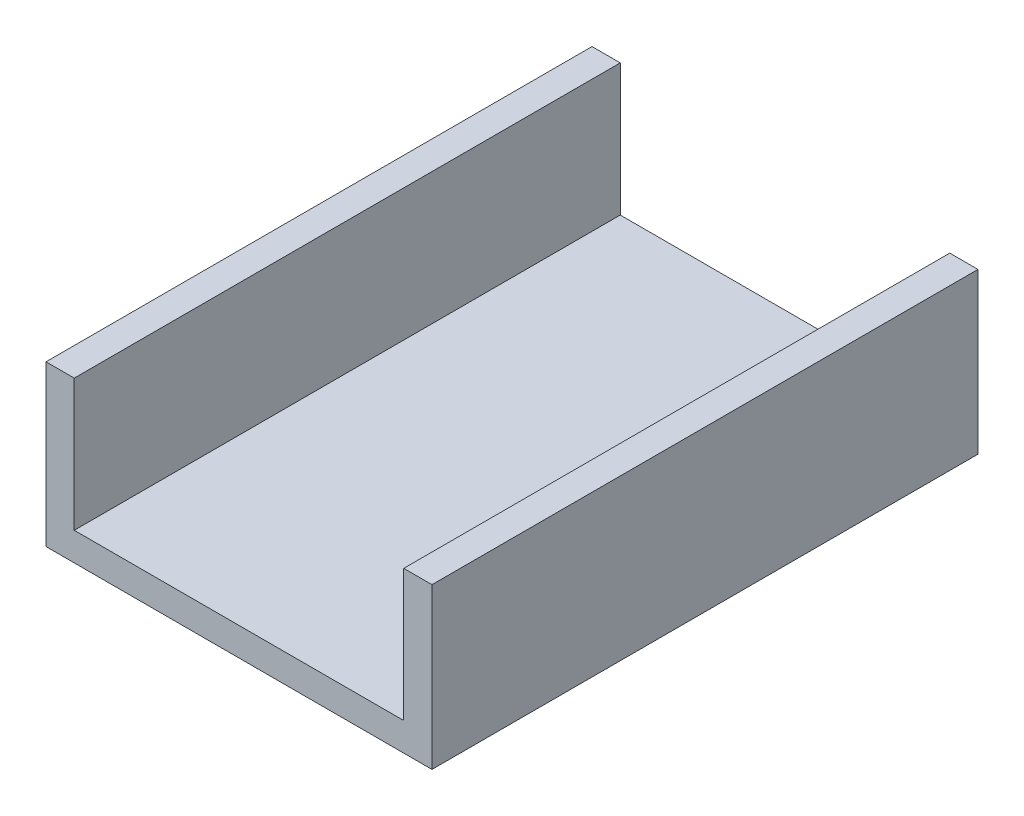
from build123d import *

# Parameters (mm, degrees)
ESQUISSE1_W        = 30
ESQUISSE1_H        = 140
ESQUISSE1_H_2      = 30
ESQUISSE1_W_2      = 350
BOSS_EXTRU_1_DEPTH = 580


with BuildPart() as part:
    # Esquisse1 → Boss.-Extru.1 (new body)
    with BuildSketch(Plane.XY):
        with Locations((-15, 100)):
            Rectangle(ESQUISSE1_W, ESQUISSE1_H)
        with Locations((-15, 15)):
            Rectangle(ESQUISSE1_W, ESQUISSE1_H_2)
        with Locations((175, 15)):
            Rectangle(ESQUISSE1_W_2, ESQUISSE1_H_2)
        with Locations((365, 15)):
            Rectangle(ESQUISSE1_W, ESQUISSE1_H_2)
        with Locations((365, 100)):
            Rectangle(ESQUISSE1_W, ESQUISSE1_H)
        Polygon((-30, 170), (-30, 152.681524316), (-15, 161.340762158), align=None)
        Polygon((-15, 161.340762158), (0, 170), (-30, 170), align=None)
        Polygon((-15, 161.340762158), (0, 152.681524316), (0, 170), align=None)
        Polygon((380, 170), (350, 170), (380, 152.681524316), align=None)
    extrude(amount=BOSS_EXTRU_1_DEPTH)


solid = part.part
